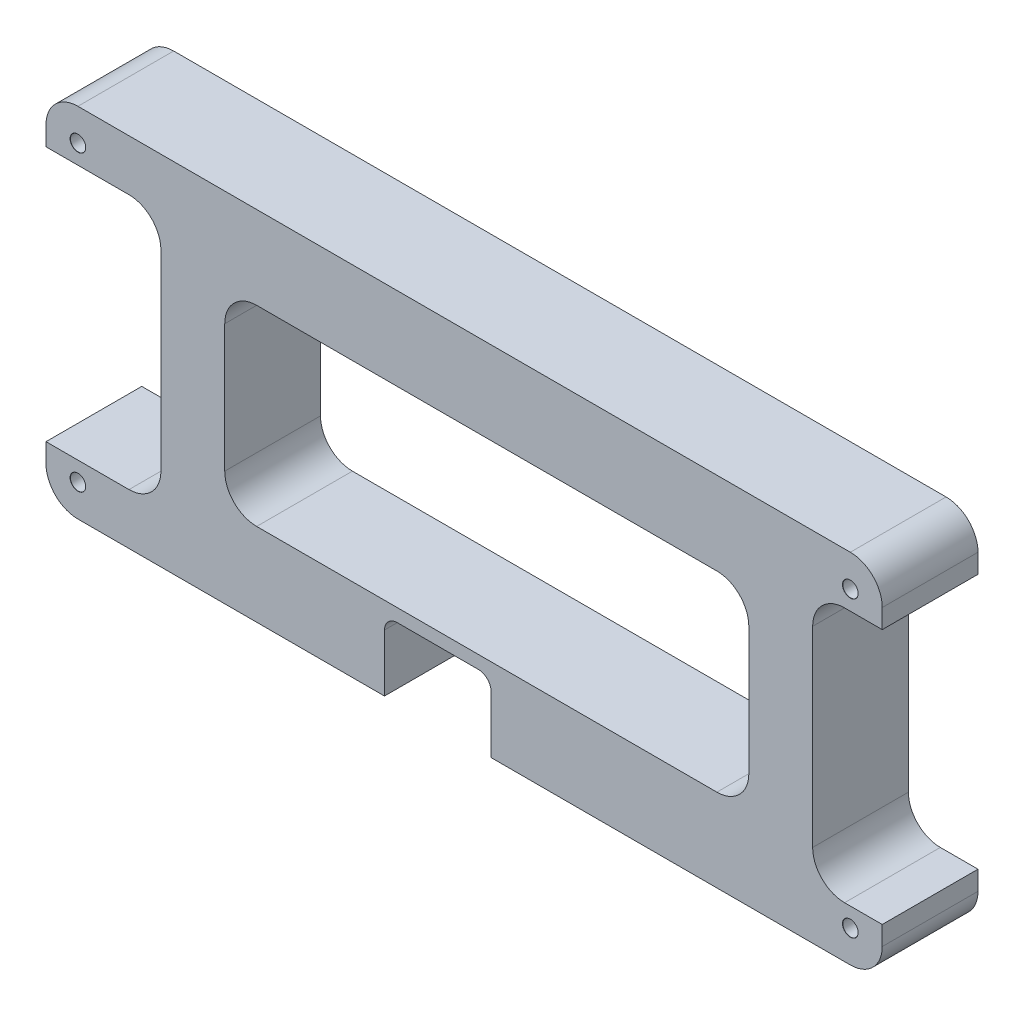
from build123d import *

# Parameters (mm, degrees)
EXTRUDE_1_DEPTH               = 15
HOLE_WIZARD_M21_D             = 2.4
HOLE_WIZARD_M21_CSINK_D       = 2.45
HOLE_WIZARD_M21_CSINK_ANGLE   = 90
HOLE_WIZARD_5_0_1_D           = 5
HOLE_WIZARD_5_0_1_DEPTH       = 3.497848452
HOLE_WIZARD_5_0_1_CSINK_D     = 5.05
HOLE_WIZARD_5_0_1_CSINK_ANGLE = 90
HOLE_WIZARD_5_0_1_TIP         = 1.502151548


with BuildPart() as part:
    # Эскиз9 → Бобышка-Вытянуть1 (new body)
    with BuildSketch(Plane.XY):
        with BuildLine():
            Line((-1.706e-06, -5.00000143), (48.02500155, -5.00000143))
            Line((48.02500155, -5.00000143), (48.02500155, 3.9624))
            ThreePointArc((48.02500155, 3.9624), (48.610787988, 5.376613562), (50.02500155, 5.9624))
            Line((50.02500155, 5.9624), (62.72500155, 5.9624))
            ThreePointArc((62.72500155, 5.9624), (64.139215112, 5.376613562), (64.72500155, 3.9624))
            Line((64.72500155, 3.9624), (64.72500155, -5.00000143))
            Line((64.72500155, -5.00000143), (120.99999946, -5.00000143))
            ThreePointArc((120.99999946, -5.00000143), (124.535533366, -3.535535336), (125.99999946, -1.43e-06))
            Line((125.99999946, -1.43e-06), (125.99999946, 2.99999857))
            Line((125.99999946, 2.99999857), (120.09775193, 2.99999857))
            ThreePointArc((120.09775193, 2.99999857), (116.562218024, 4.464464664), (115.09775193, 7.99999857))
            Line((115.09775193, 7.99999857), (115.09775193, 37.99999857))
            ThreePointArc((115.09775193, 37.99999857), (116.562218024, 41.535532476), (120.09775193, 42.99999857))
            Line((120.09775193, 42.99999857), (125.99999946, 42.99999857))
            Line((125.99999946, 42.99999857), (125.99999946, 45.99999857))
            ThreePointArc((125.99999946, 45.99999857), (124.535533366, 49.535532476), (120.99999946, 50.99999857))
            Line((120.99999946, 50.99999857), (-1.706e-06, 50.99999857))
            ThreePointArc((-1.706e-06, 50.99999857), (-3.535534858, 49.535532064), (-5.00000054, 45.99999857))
            Line((-5.00000054, 45.99999857), (-5.00000054, 42.99999857))
            Line((-5.00000054, 42.99999857), (7.999998294, 42.99999857))
            ThreePointArc((7.999998294, 42.99999857), (11.5355322, 41.535532476), (12.999998294, 37.99999857))
            Line((12.999998294, 37.99999857), (12.999998294, 7.99999857))
            ThreePointArc((12.999998294, 7.99999857), (11.5355322, 4.464464664), (7.999998294, 2.99999857))
            Line((7.999998294, 2.99999857), (-5.000001706, 2.99999857))
            Line((-5.000001706, 2.99999857), (-5.000001706, -1.43e-06))
            ThreePointArc((-5.000001706, -1.43e-06), (-3.535535612, -3.535535336), (-1.706e-06, -5.00000143))
        make_face()
        with BuildLine():
            Line((27.999998294, 37.99999857), (100.09775193, 37.99999857))
            ThreePointArc((100.09775193, 37.99999857), (103.633285836, 36.535532476), (105.09775193, 32.99999857))
            Line((105.09775193, 32.99999857), (105.09775193, 12.99999857))
            ThreePointArc((105.09775193, 12.99999857), (103.633285836, 9.464464664), (100.09775193, 7.99999857))
            Line((100.09775193, 7.99999857), (27.999998294, 7.99999857))
            ThreePointArc((27.999998294, 7.99999857), (24.464464388, 9.464464664), (22.999998294, 12.99999857))
            Line((22.999998294, 12.99999857), (22.999998294, 32.99999857))
            ThreePointArc((22.999998294, 32.99999857), (24.464464388, 36.535532476), (27.999998294, 37.99999857))
        make_face(mode=Mode.SUBTRACT)
    extrude(amount=-EXTRUDE_1_DEPTH)

    # Отверстие с зазором M21 (through all)
    with Locations(Plane.XY):
        with Locations((1.27e-06, 45.99999944), (0, 0), (120.9999993, -1.27e-06), (120.9999993, 45.99999944)):
            CounterSinkHole(HOLE_WIZARD_M21_D / 2, HOLE_WIZARD_M21_CSINK_D / 2, counter_sink_angle=HOLE_WIZARD_M21_CSINK_ANGLE)

    # Отверстия под штифты Ø5.0 мм1
    with Locations(Plane(origin=(0, 0, -15), x_dir=(-1, 0, 0), z_dir=(0, 0, -1))):
        with Locations((-120.9999993, -1.27e-06), (-120.9999993, 45.99999944), (-1.27e-06, 45.99999944), (0, 0), (-55.116594528, 0)):
            CounterSinkHole(HOLE_WIZARD_5_0_1_D / 2, HOLE_WIZARD_5_0_1_CSINK_D / 2, depth=HOLE_WIZARD_5_0_1_DEPTH, counter_sink_angle=HOLE_WIZARD_5_0_1_CSINK_ANGLE)
            with Locations((0, 0, -(HOLE_WIZARD_5_0_1_DEPTH + HOLE_WIZARD_5_0_1_TIP / 2))):  # 118° drill point
                Cone(0, HOLE_WIZARD_5_0_1_D / 2, HOLE_WIZARD_5_0_1_TIP, mode=Mode.SUBTRACT)


solid = part.part
